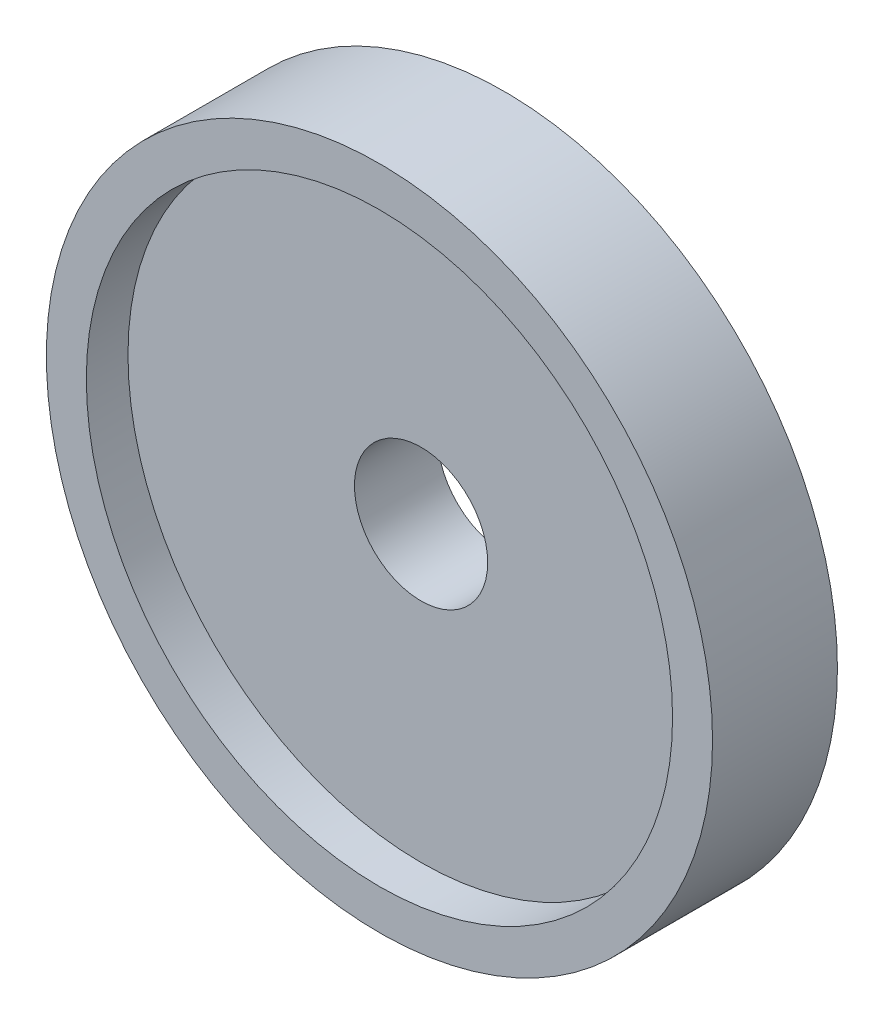
from build123d import *


with BuildPart() as part:
    # Sketch1 → Revolve1 (revolve)
    with BuildSketch(Plane(origin=(0, 0, 0), x_dir=(1, 0, 0), z_dir=(0, 1, 0))):
        Polygon((2, -0.75), (2, 0), (0.4, 0), (0.4, -0.5), (1.76, -0.5), (1.76, -0.75), align=None)
    revolve(axis=Axis((0, 0, 0), (0, 0, 1)))


solid = part.part
